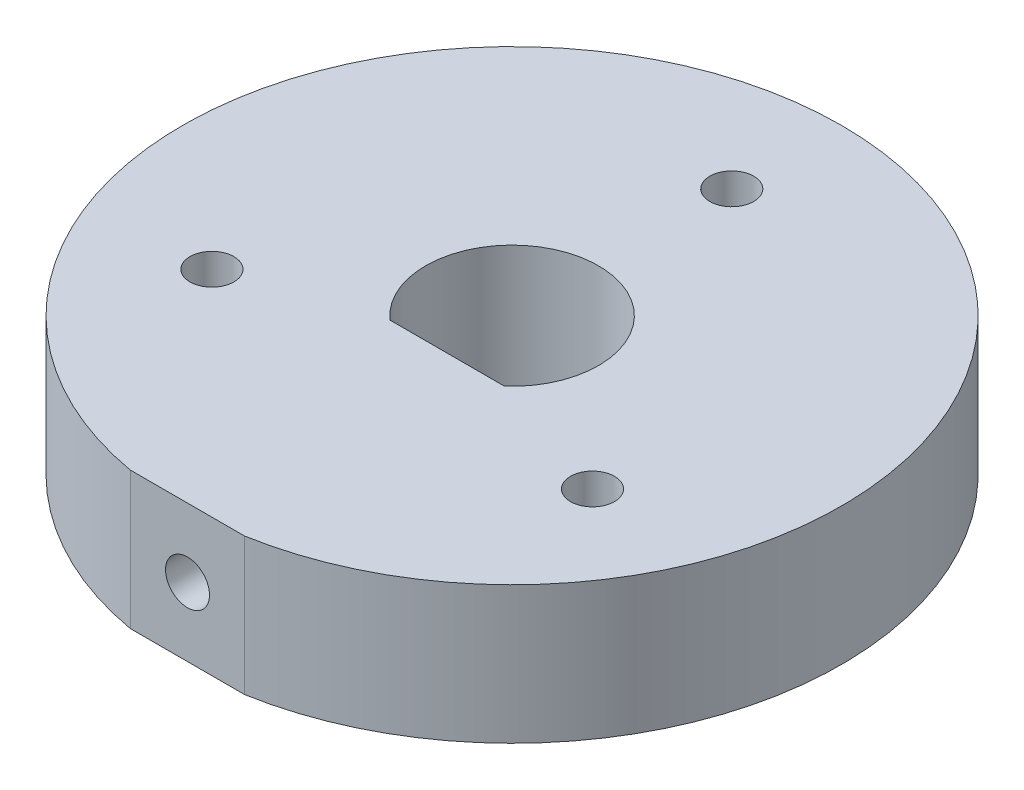
from build123d import *

# Parameters (mm, degrees)
SKETCH1_R           = 1.016
BOSS_EXTRUDE1_DEPTH = 6.35
CUT_EXTRUDE1_REACH  = 32.249
SKETCH2_R           = 1.016


with BuildPart() as part:
    # Sketch1 → Boss-Extrude1 (new body)
    with BuildSketch(Plane(origin=(0, 0, 0), x_dir=(1, 0, 0), z_dir=(0, 1, 0))):
        with BuildLine():
            Line((-2.645751311, -15.00858421), (2.645751311, -15.00858421))
            ThreePointArc((2.645751311, -15.00858421), (0, 15.24), (-2.645751311, -15.00858421))
        make_face()
        with Locations((0, 10.16)):
            Circle(SKETCH1_R, mode=Mode.SUBTRACT)
        with Locations((8.798818102, -5.08)):
            Circle(SKETCH1_R, mode=Mode.SUBTRACT)
        with Locations((-8.798818102, -5.08)):
            Circle(SKETCH1_R, mode=Mode.SUBTRACT)
        with BuildLine():
            Line((-2.645751311, -3), (2.645751311, -3))
            ThreePointArc((2.645751311, -3), (0, 4), (-2.645751311, -3))
        make_face(mode=Mode.SUBTRACT)
    extrude(amount=BOSS_EXTRUDE1_DEPTH)

    # Sketch2 → Cut-Extrude1 (cut, up to next)
    with BuildSketch(Plane.XY.offset(15.00858421), mode=Mode.PRIVATE) as cut_extrude1_sk1:
        with Locations((0, 3.175)):
            Circle(SKETCH2_R)
    cut_extrude1_tool1 = extrude(cut_extrude1_sk1.sketch, amount=-CUT_EXTRUDE1_REACH, mode=Mode.PRIVATE) & part.part
    add(cut_extrude1_tool1.solids().sort_by_distance((0, 3.175, 15.008584))[0], mode=Mode.SUBTRACT)


solid = part.part
